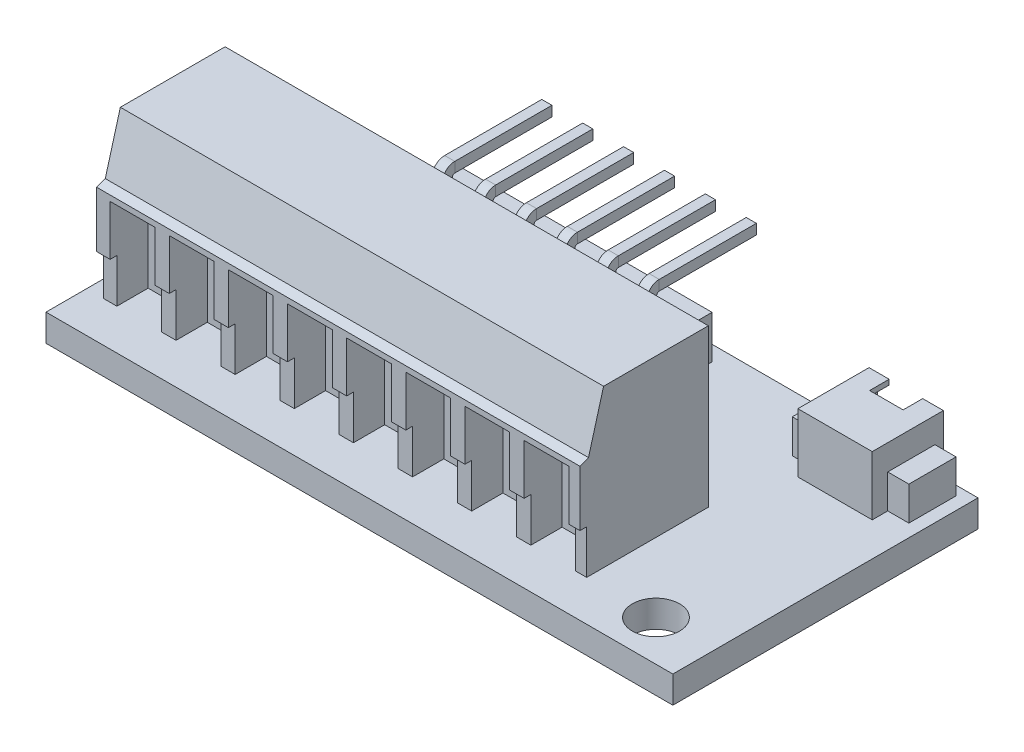
from build123d import *

# Parameters (mm, degrees)
SKETCH1_W           = 37.1
SKETCH1_H           = 18.06
SKETCH1_R           = 1.4
BOSS_EXTRUDE1_DEPTH = 1.6
SKETCH2_W           = 0.7
SKETCH2_H           = 1.5
BOSS_EXTRUDE2_DEPTH = 2.54
SKETCH4_W           = 0.6
SKETCH4_H           = 0.6
LPATTERN1_COUNT     = 6
LPATTERN1_PITCH     = 2.42
SKETCH6_W           = 28.6
SKETCH6_H           = 7.6
BOSS_EXTRUDE3_DEPTH = 9.3
CUT_EXTRUDE1_REACH  = 38.1
SKETCH7_W           = 0.4
SKETCH7_H           = 2.6
SKETCH8_W           = 2.65
SKETCH8_H           = 5.571671588
CUT_EXTRUDE2_DEPTH  = 2.25
SKETCH9_W           = 4.4
SKETCH9_H           = 4.21
BOSS_EXTRUDE4_DEPTH = 3.5
SKETCH10_W          = 6.9
SKETCH10_H          = 2.792271398
BOSS_EXTRUDE5_DEPTH = 2
SKETCH11_W          = 3.3
SKETCH11_H          = 2.7
CUT_EXTRUDE3_DEPTH  = 3.5
CUT_EXTRUDE4_REACH  = 7.1
SKETCH12_W          = 1.985213288
SKETCH12_H          = 1.157017581


with BuildPart() as part:
    # Sketch1 → Boss-Extrude1 (new body)
    with BuildSketch(Plane(origin=(0, 0, 0), x_dir=(1, 0, 0), z_dir=(0, 1, 0))):
        with Locations((18.55, 9.03)):
            Rectangle(SKETCH1_W, SKETCH1_H)
        with Locations(Location((33.7, 2.4, 0), (0, 0, 270))):  # turned: the seam where the file's is
            Circle(SKETCH1_R, mode=Mode.SUBTRACT)
        with Locations(Location((2.8, 14.16, 0), (0, 0, 270))):  # turned: the seam where the file's is
            Circle(SKETCH1_R, mode=Mode.SUBTRACT)
    extrude(amount=BOSS_EXTRUDE1_DEPTH)

    # Sketch2 → Boss-Extrude2 (add)
    with BuildSketch(Plane(origin=(0, 1.6, 0), x_dir=(1, 0, 0), z_dir=(0, 1, 0))):
        Polygon((7.060184456, 17.16), (22.260184456, 17.16), (22.260184456, 15.56), (21.580184456, 15.56), (21.580184456, 14.06), (22.260184456, 14.06), (22.260184456, 12.46), (7.060184456, 12.46), (7.060184456, 14.06), (7.760184456, 14.06), (7.760184456, 15.56), (7.060184456, 15.56), align=None)
        with Locations((9.830184456, 14.81)):
            Rectangle(SKETCH2_W, SKETCH2_H, mode=Mode.SUBTRACT)
        with Locations((12.250184456, 14.81)):
            Rectangle(SKETCH2_W, SKETCH2_H, mode=Mode.SUBTRACT)
        with Locations((14.670184456, 14.81)):
            Rectangle(SKETCH2_W, SKETCH2_H, mode=Mode.SUBTRACT)
        with Locations((17.090184456, 14.81)):
            Rectangle(SKETCH2_W, SKETCH2_H, mode=Mode.SUBTRACT)
        with Locations((19.510184456, 14.81)):
            Rectangle(SKETCH2_W, SKETCH2_H, mode=Mode.SUBTRACT)
    extrude(amount=BOSS_EXTRUDE2_DEPTH)

    # Sweep1: sweep along a path in Sketch3
    with BuildLine(Plane.ZY.offset(-8.610184456)) as sweep1_path:
        Line((-14.533057121, 4.14), (-14.533057121, 5.39))
        ThreePointArc((-14.533057121, 5.39), (-14.752727035, 5.920330086), (-15.283057121, 6.14))
        Line((-15.283057121, 6.14), (-21.033057121, 6.14))
    # Sketch4 → Sweep1 (sweep)
    with BuildSketch(Plane(origin=(0, 4.14, 0), x_dir=(1, 0, 0), z_dir=(0, 1, 0))):
        with Locations((8.610184456, 14.833057121)):
            Rectangle(SKETCH4_W, SKETCH4_H)
    sweep1 = sweep(path=sweep1_path.line)

    # LPattern1: Sweep1 ×6
    with Locations(*[(i * LPATTERN1_PITCH, 0, 0) for i in range(1, LPATTERN1_COUNT)]):
        add(sweep1)

    # Sketch6 → Boss-Extrude3 (add)
    with BuildSketch(Plane(origin=(0, 1.6, 0), x_dir=(1, 0, 0), z_dir=(0, 1, 0))):
        with Locations((15.3, 5.8)):
            Rectangle(SKETCH6_W, SKETCH6_H)
    extrude(amount=BOSS_EXTRUDE3_DEPTH)

    # Sketch7 → Cut-Extrude1 (cut, up to next)
    with BuildSketch(Plane.ZY.offset(-1), mode=Mode.PRIVATE) as cut_extrude1_sk1:
        Polygon((-2, 7.5), (-2.508141267, 7.68870454), (-3.4, 10.9), (-2, 10.9), align=None)
    cut_extrude1_tool1 = extrude(cut_extrude1_sk1.sketch, amount=-CUT_EXTRUDE1_REACH, mode=Mode.PRIVATE) & part.part
    add(cut_extrude1_tool1.solids().sort_by_distance((1, 9.514948, -2.506498))[0], mode=Mode.SUBTRACT)
    # Sketch7 → Cut-Extrude1 (cut, up to next)
    with BuildSketch(Plane.ZY.offset(-1), mode=Mode.PRIVATE) as cut_extrude1_sk2:
        with Locations((-2.2, 2.9)):
            Rectangle(SKETCH7_W, SKETCH7_H)
    cut_extrude1_tool2 = extrude(cut_extrude1_sk2.sketch, amount=-CUT_EXTRUDE1_REACH, mode=Mode.PRIVATE) & part.part
    add(cut_extrude1_tool2.solids().sort_by_distance((1, 2.9, -2.2))[0], mode=Mode.SUBTRACT)

    # Sketch8 → Cut-Extrude2 (cut)
    with BuildSketch(Plane.XY.offset(-2)):
        with Locations((3.120484252, 4.385835794)):
            Rectangle(SKETCH8_W, SKETCH8_H)
        with Locations((6.620484252, 4.385835794)):
            Rectangle(SKETCH8_W, SKETCH8_H)
        with Locations((10.120484252, 4.385835794)):
            Rectangle(SKETCH8_W, SKETCH8_H)
        with Locations((13.620484252, 4.385835794)):
            Rectangle(SKETCH8_W, SKETCH8_H)
        with Locations((17.120484252, 4.385835794)):
            Rectangle(SKETCH8_W, SKETCH8_H)
        with Locations((20.620484252, 4.385835794)):
            Rectangle(SKETCH8_W, SKETCH8_H)
        with Locations((24.120484252, 4.385835794)):
            Rectangle(SKETCH8_W, SKETCH8_H)
        with Locations((27.620484252, 4.385835794)):
            Rectangle(SKETCH8_W, SKETCH8_H)
    extrude(amount=-CUT_EXTRUDE2_DEPTH, mode=Mode.SUBTRACT)

    # Sketch9 → Boss-Extrude4 (add)
    with BuildSketch(Plane(origin=(0, 1.6, 0), x_dir=(1, 0, 0), z_dir=(0, 1, 0))):
        with Locations((32.9, 15.905)):
            Rectangle(SKETCH9_W, SKETCH9_H)
    extrude(amount=BOSS_EXTRUDE4_DEPTH)

    # Sketch10 → Boss-Extrude5 (add)
    with BuildSketch(Plane(origin=(0, 1.6, 0), x_dir=(1, 0, 0), z_dir=(0, 1, 0))):
        with Locations((32.9, 16.113864301)):
            Rectangle(SKETCH10_W, SKETCH10_H)
    extrude(amount=BOSS_EXTRUDE5_DEPTH)

    # Sketch11 → Cut-Extrude3 (cut)
    with BuildSketch(Plane(origin=(0, 0, -18.01), x_dir=(-1, 0, 0), z_dir=(0, 0, -1))):
        with Locations((-32.852042443, 3.45)):
            Rectangle(SKETCH11_W, SKETCH11_H)
    extrude(amount=-CUT_EXTRUDE3_DEPTH, mode=Mode.SUBTRACT)

    # Sketch12 → Cut-Extrude4 (cut, up to next)
    with BuildSketch(Plane(origin=(0, 5.1, 0), x_dir=(1, 0, 0), z_dir=(0, 1, 0)), mode=Mode.PRIVATE) as cut_extrude4_sk1:
        with Locations((32.883783696, 17.43149121)):
            Rectangle(SKETCH12_W, SKETCH12_H)
    cut_extrude4_tool1 = extrude(cut_extrude4_sk1.sketch, amount=-CUT_EXTRUDE4_REACH, mode=Mode.PRIVATE) & part.part
    add(cut_extrude4_tool1.solids().sort_by_distance((32.883784, 5.1, -17.431491))[0], mode=Mode.SUBTRACT)


solid = part.part
